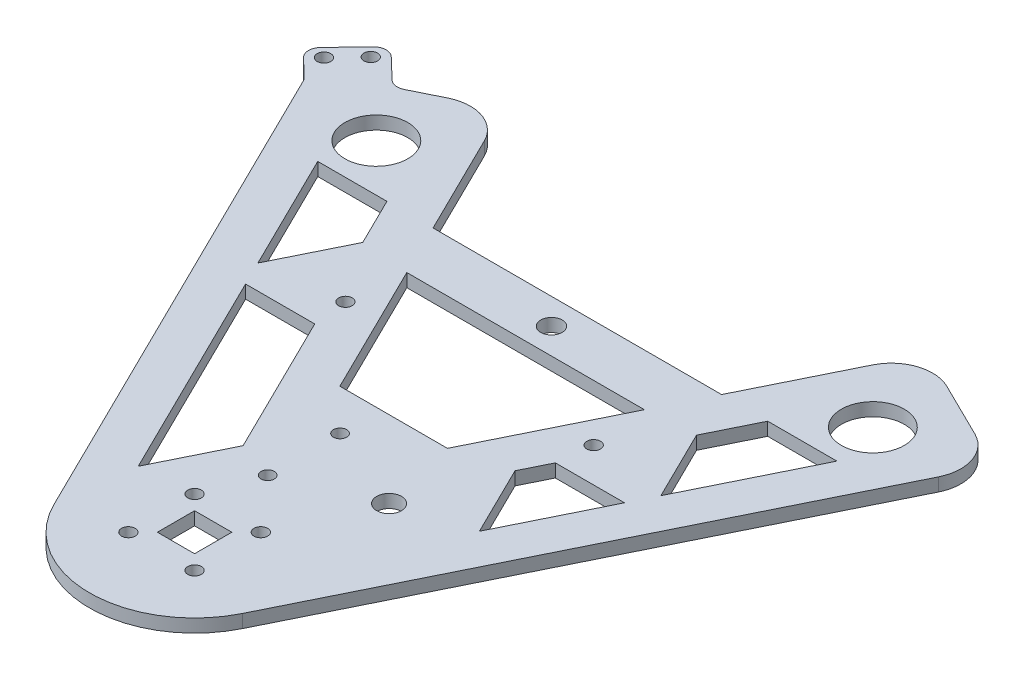
from build123d import *

# Parameters (mm, degrees)
SKETCH1_R               = 1.65
SKETCH1_W               = 9
SKETCH1_H               = 9
SKETCH1_R_2             = 1.6
SKETCH1_R_3             = 3
SKETCH1_R_4             = 7.6
SKETCH1_R_5             = 2.6
BOSS_EXTRUDE1_DEPTH     = 3.175
FILLET1_R               = 10
CUT_EXTRUDE1_DEPTH      = 1
CUT_EXTRUDE1_DEPTH_BACK = 4.175
SKETCH3_R               = 1.65
BOSS_EXTRUDE2_DEPTH     = 3.175
FILLET2_R               = 3


with BuildPart() as part:
    # Sketch1 → Boss-Extrude1 (new body)
    with BuildSketch(Plane(origin=(0, 0, 0), x_dir=(1, 0, 0), z_dir=(0, 1, 0))):
        with BuildLine():
            Line((-51.31658538, 125.897213638), (-82.713802404, 110.430644428))
            Line((-82.713802404, 110.430644428), (-22.785408926, -11.224310227))
            ThreePointArc((-22.785408926, -11.224310227), (0, -25.4), (22.785408926, -11.224310227))
            Line((22.785408926, -11.224310227), (82.713802404, 110.430644428))
            Line((82.713802404, 110.430644428), (51.31658538, 125.897213638))
            Line((51.31658538, 125.897213638), (34.864798721, 92.5))
            Line((34.864798721, 92.5), (-34.864798721, 92.5))
            Line((-34.864798721, 92.5), (-51.31658538, 125.897213638))
        make_face()
        Polygon((-28.707179242, 80), (28.707179242, 80), (13, 48.114343343), (-13, 48.114343343), align=None, mode=Mode.SUBTRACT)
        with Locations((-8, -8)):
            Circle(SKETCH1_R, mode=Mode.SUBTRACT)
        Rectangle(SKETCH1_W, SKETCH1_H, mode=Mode.SUBTRACT)
        with Locations((-8, 8)):
            Circle(SKETCH1_R, mode=Mode.SUBTRACT)
        with Locations((-3.1, 20.76053754)):
            Circle(SKETCH1_R_2, mode=Mode.SUBTRACT)
        with Locations((8, -8)):
            Circle(SKETCH1_R, mode=Mode.SUBTRACT)
        with Locations((8, 8)):
            Circle(SKETCH1_R, mode=Mode.SUBTRACT)
        with Locations((17.5, 29.51053754)):
            Circle(SKETCH1_R_3, mode=Mode.SUBTRACT)
        with Locations((-30, 66.453060464)):
            Circle(SKETCH1_R, mode=Mode.SUBTRACT)
        with Locations((-60, 103.923048454)):
            Circle(SKETCH1_R_4, mode=Mode.SUBTRACT)
        with Locations((30, 66.453060464)):
            Circle(SKETCH1_R, mode=Mode.SUBTRACT)
        with Locations((60, 103.923048454)):
            Circle(SKETCH1_R_4, mode=Mode.SUBTRACT)
        with Locations((0, 86.25)):
            Circle(SKETCH1_R_5, mode=Mode.SUBTRACT)
        with Locations((-3.1, 38.26053754)):
            Circle(SKETCH1_R_2, mode=Mode.SUBTRACT)
    extrude(amount=BOSS_EXTRUDE1_DEPTH)

    # Fillet1
    fillet1_edges = [part.edges().sort_by_distance(p)[0] for p in [
        (51.31658538, 1.5875, -125.897213638),
        (82.713802404, 1.5875, -110.430644428),
        (-82.713802404, 1.5875, -110.430644428),
        (-51.31658538, 1.5875, -125.897213638),
    ]]
    fillet(fillet1_edges, radius=FILLET1_R)

    # Sketch2 → Cut-Extrude1 (cut, two sides)
    with BuildSketch(Plane(origin=(0, 3.175, 0), x_dir=(1, 0, 0), z_dir=(0, 1, 0))) as cut_extrude1_sk:
        Polygon((-45.79480762, 58.114343343), (-29.073580398, 58.114343343), (-12.254779912, 23.972089701), (-20.615393523, 7), align=None)
        Polygon((-62.733510758, 92.5), (-48.694138346, 64), (-40.333524735, 80.972089701), (-46.012283536, 92.5), align=None)
        Polygon((29.073580398, 58.114343343), (45.79480762, 58.114343343), (34.218483, 34.614343343), (25.857869389, 51.586433044), align=None)
        Polygon((46.012283536, 92.5), (62.733510758, 92.5), (48.694138346, 64), (40.333524735, 80.972089701), align=None)
    extrude(amount=CUT_EXTRUDE1_DEPTH, mode=Mode.SUBTRACT)
    extrude(cut_extrude1_sk.sketch, amount=-CUT_EXTRUDE1_DEPTH_BACK, mode=Mode.SUBTRACT)

    # Sketch3 → Boss-Extrude2 (add)
    with BuildSketch(Plane(origin=(0, 0, 0), x_dir=(1, 0, 0), z_dir=(0, 1, 0))):
        with BuildLine():
            Line((-69.257852251, 117.059174089), (-77.922641378, 125.361067209))
            Line((-77.922641378, 125.361067209), (-88.300007778, 114.5300808))
            Line((-88.300007778, 114.5300808), (-81.545013782, 108.057997365))
            Line((-81.545013782, 108.057997365), (-78.29478263, 101.460010992))
            ThreePointArc((-78.29478263, 101.460010992), (-78.792063776, 109.097507652), (-73.743168968, 114.849664202))
            Line((-73.743168968, 114.849664202), (-69.257852251, 117.059174089))
        make_face()
        with Locations((-78.17782959, 120.758363767)):
            Circle(SKETCH3_R, mode=Mode.SUBTRACT)
        with Locations((-83.712425003, 114.981837682)):
            Circle(SKETCH3_R, mode=Mode.SUBTRACT)
    extrude(amount=BOSS_EXTRUDE2_DEPTH)

    # Fillet2
    fillet2_edges = [part.edges().sort_by_distance(p)[0] for p in [
        (-81.545013782, 1.5875, -108.057997365),
        (-88.300007778, 1.5875, -114.5300808),
        (-77.922641378, 1.5875, -125.361067209),
        (-69.257852251, 1.5875, -117.059174089),
    ]]
    fillet(fillet2_edges, radius=FILLET2_R)


solid = part.part
